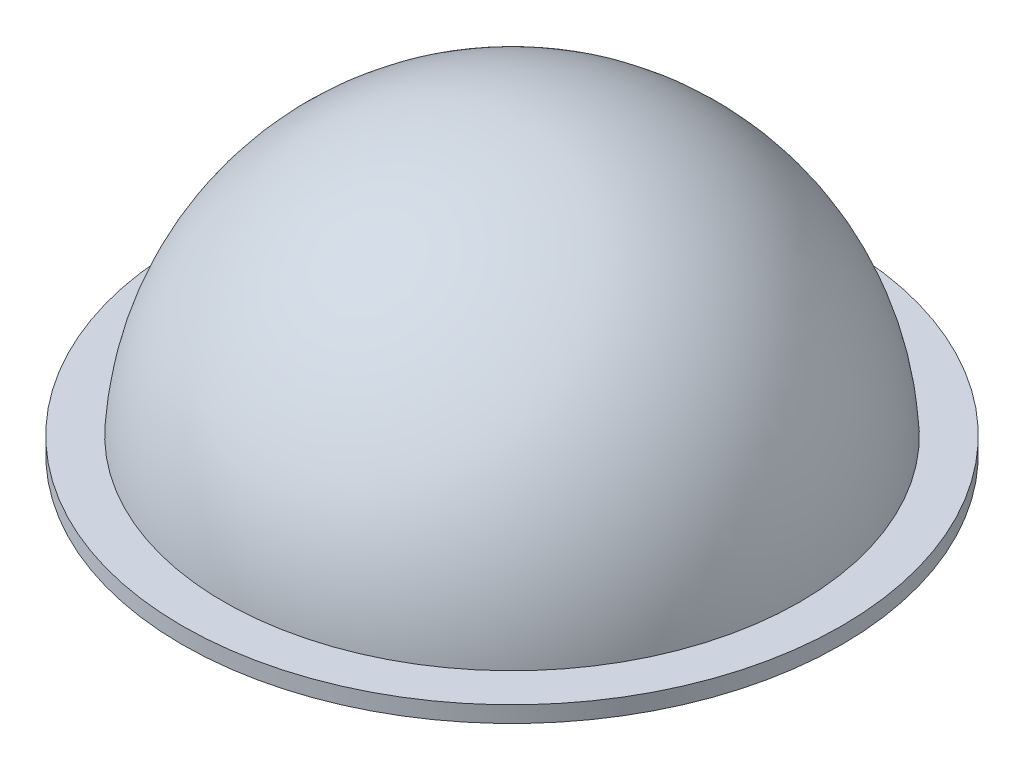
from build123d import *


with BuildPart() as part:
    # Sketch1 → Revolve1 (revolve)
    with BuildSketch(Plane.XY):
        with BuildLine():
            Line((-101.6, 0), (-101.6, 5))
            Line((-101.6, 5), (-88.759281205, 5))
            ThreePointArc((-88.759281205, 5), (-61.068445207, 64.605379033), (0, 88.9))
            Line((0, 88.9), (0, 85.725))
            ThreePointArc((0, 85.725), (-60.616728817, 60.616728817), (-85.725, 0))
            Line((-85.725, 0), (-101.6, 0))
        make_face()
    revolve(axis=Axis((0, 0, 0), (0, 1, 0)))


solid = part.part
